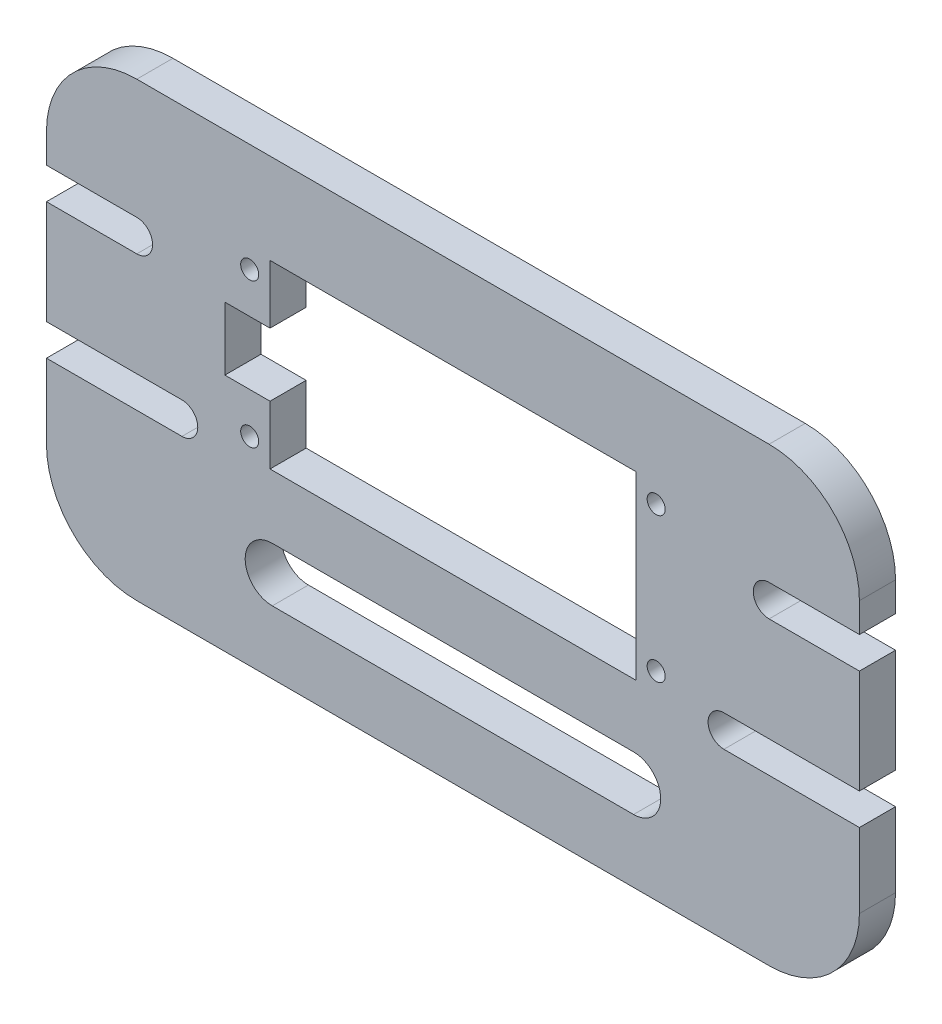
from build123d import *

# Parameters (mm, degrees)
SKETCH_1_R          = 3
SKETCH_1_W          = 40
SKETCH_1_H          = 20
EXTRUDE_1_DEPTH     = 4
EXTRUDE_3_DEPTH     = 4
SKETCH_3_R          = 3
EXTRUDE_4_DEPTH     = 4
SKETCH_4_R          = 1
CUT_EXTRUDE_1_DEPTH = 4
SKETCH_5_R          = 1
CUT_EXTRUDE_2_DEPTH = 5
SKETCH_6_W          = 5
SKETCH_6_H          = 7
SKETCH_6_W_2        = 40.5
SKETCH_6_H_2        = 20
SKETCH_6_R          = 1
SKETCH_6_W_3        = 22
SKETCH_6_H_3        = 12
CUT_EXTRUDE_3_DEPTH = 10


with BuildPart() as part:
    # 草图1 → 凸台-拉伸1 (new body)
    with BuildSketch(Plane.XY):
        with BuildLine():
            ThreePointArc((-45, -15), (-42.071067812, -22.071067812), (-35, -25))
            Line((-35, -25), (35, -25))
            ThreePointArc((35, -25), (42.071067812, -22.071067812), (45, -15))
            Line((45, -15), (45, -6.75))
            Line((45, -6.75), (30, -6.75))
            ThreePointArc((30, -6.75), (28.25, -5), (30, -3.25))
            Line((30, -3.25), (45, -3.25))
            Line((45, -3.25), (45, 8.25))
            Line((45, 8.25), (35, 8.25))
            ThreePointArc((35, 8.25), (33.25, 10), (35, 11.75))
            Line((35, 11.75), (45, 11.75))
            Line((45, 11.75), (45, 15))
            ThreePointArc((45, 15), (42.071067812, 22.071067812), (35, 25))
            Line((35, 25), (-35, 25))
            ThreePointArc((-35, 25), (-42.071067812, 22.071067812), (-45, 15))
            Line((-45, 15), (-45, 11.75))
            Line((-45, 11.75), (-35, 11.75))
            ThreePointArc((-35, 11.75), (-33.25, 10), (-35, 8.25))
            Line((-35, 8.25), (-45, 8.25))
            Line((-45, 8.25), (-45, -3.25))
            Line((-45, -3.25), (-30, -3.25))
            ThreePointArc((-30, -3.25), (-28.25, -5), (-30, -6.75))
            Line((-30, -6.75), (-45, -6.75))
            Line((-45, -6.75), (-45, -15))
        make_face()
        with BuildLine():
            ThreePointArc((-20, -18), (-23, -15), (-20, -12))
            Line((-20, -12), (20, -12))
            ThreePointArc((20, -12), (23, -15), (20, -18))
            Line((20, -18), (-20, -18))
        make_face(mode=Mode.SUBTRACT)
        with Locations((-24, 0)):
            Circle(SKETCH_1_R, mode=Mode.SUBTRACT)
        with Locations((-24, 10)):
            Circle(SKETCH_1_R, mode=Mode.SUBTRACT)
        with Locations((0, 5)):
            Rectangle(SKETCH_1_W, SKETCH_1_H, mode=Mode.SUBTRACT)
        with Locations((24, 0)):
            Circle(SKETCH_1_R, mode=Mode.SUBTRACT)
        with Locations((24, 10)):
            Circle(SKETCH_1_R, mode=Mode.SUBTRACT)
    extrude(amount=EXTRUDE_1_DEPTH)

    # 草图2 → 凸台-拉伸3 (add)
    with BuildSketch(Plane.XY.offset(4)):
        Polygon((20, -5), (20, 5), (11, 5), (11, -1), (-11, -1), (-11, 5), (-20, 5), (-20, -5), align=None)
        Polygon((11, 5), (20, 5), (20, 15), (-20, 15), (-20, 5), (-11, 5), (-11, 11), (11, 11), align=None)
    extrude(amount=-EXTRUDE_3_DEPTH)

    # 草图3 → 凸台-拉伸4 (add)
    with BuildSketch(Plane.XY.offset(4)):
        with Locations((-24, 10)):
            Circle(SKETCH_3_R)
        with Locations((-24, 0)):
            Circle(SKETCH_3_R)
        with Locations((24, 10)):
            Circle(SKETCH_3_R)
        with Locations((24, 0)):
            Circle(SKETCH_3_R)
    extrude(amount=-EXTRUDE_4_DEPTH)

    # 草图4 → 切除-拉伸1 (cut)
    with BuildSketch(Plane.XY.offset(4)):
        with Locations((-14, 5)):
            Circle(SKETCH_4_R)
        with Locations((14, 5)):
            Circle(SKETCH_4_R)
    extrude(amount=-CUT_EXTRUDE_1_DEPTH, mode=Mode.SUBTRACT)

    # 草图5 → 切除-拉伸2 (cut, through all)
    with BuildSketch(Plane.XY.offset(4)):
        with Locations((-22.5, -3)):
            Circle(SKETCH_5_R)
        with Locations((-22.5, 13)):
            Circle(SKETCH_5_R)
    cut_extrude_2 = extrude(amount=-CUT_EXTRUDE_2_DEPTH, mode=Mode.SUBTRACT)

    # 镜向1: 切除-拉伸2 across plane
    add(cut_extrude_2.mirror(Plane(origin=(0, 0, 0), x_dir=(0, 0, 1), z_dir=(1, 0, 0))), mode=Mode.SUBTRACT)

    # 草图6 → 切除-拉伸3 (cut)
    with BuildSketch(Plane.XY.offset(4)):
        with Locations((-22.75, 5)):
            Rectangle(SKETCH_6_W, SKETCH_6_H)
        with Locations((0, 5)):
            Rectangle(SKETCH_6_W_2, SKETCH_6_H_2)
        with Locations((14, 5)):
            Circle(SKETCH_6_R, mode=Mode.SUBTRACT)
        with Locations((-14, 5)):
            Circle(SKETCH_6_R, mode=Mode.SUBTRACT)
        with Locations((0, 5)):
            Rectangle(SKETCH_6_W_3, SKETCH_6_H_3, mode=Mode.SUBTRACT)
    extrude(amount=-CUT_EXTRUDE_3_DEPTH, mode=Mode.SUBTRACT)


solid = part.part
